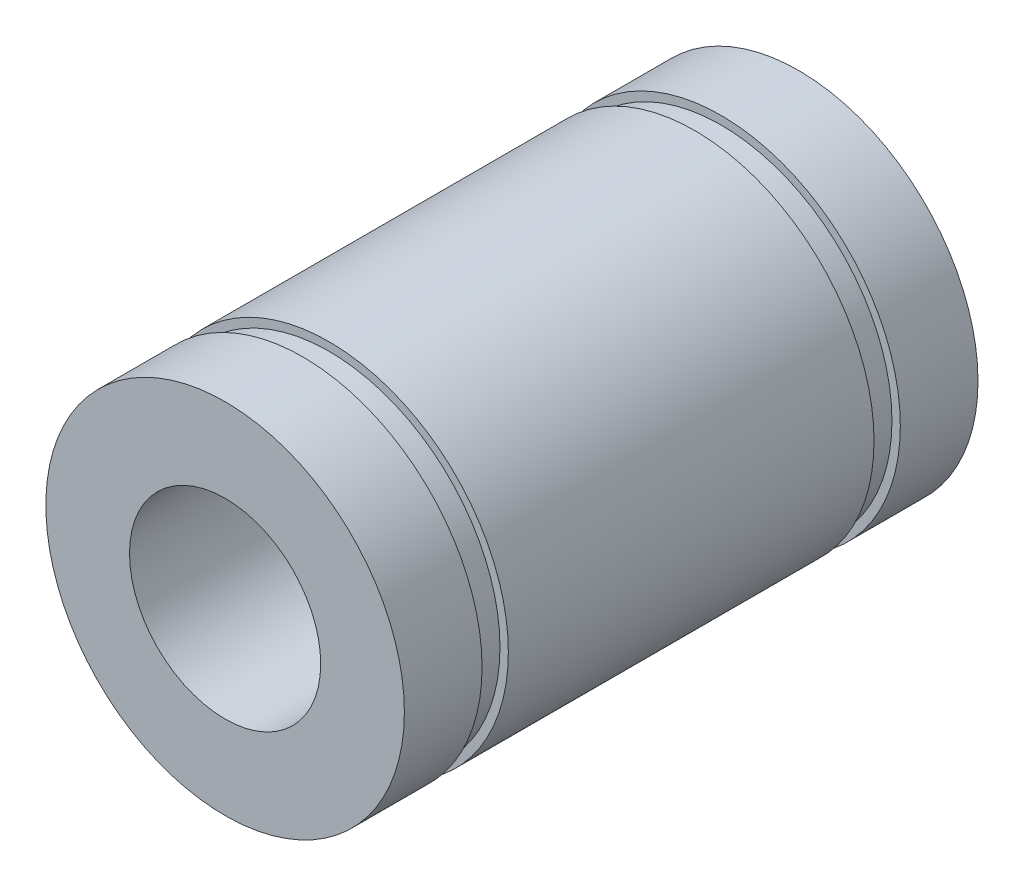
from build123d import *


with BuildPart() as part:
    # Sketch1 → Revolve1 (revolve)
    with BuildSketch(Plane(origin=(0, 0, 0), x_dir=(1, 0, 0), z_dir=(0, 1, 0))):
        Polygon((7.5, 0), (4, 0), (4, -24), (7.5, -24), (7.5, -20.75), (7.15, -20.75), (7.15, -19.65), (7.5, -19.65), (7.5, -4.35), (7.15, -4.35), (7.15, -3.25), (7.5, -3.25), align=None)
    revolve(axis=Axis((0, 0, 0), (0, 0, 1)))


solid = part.part
